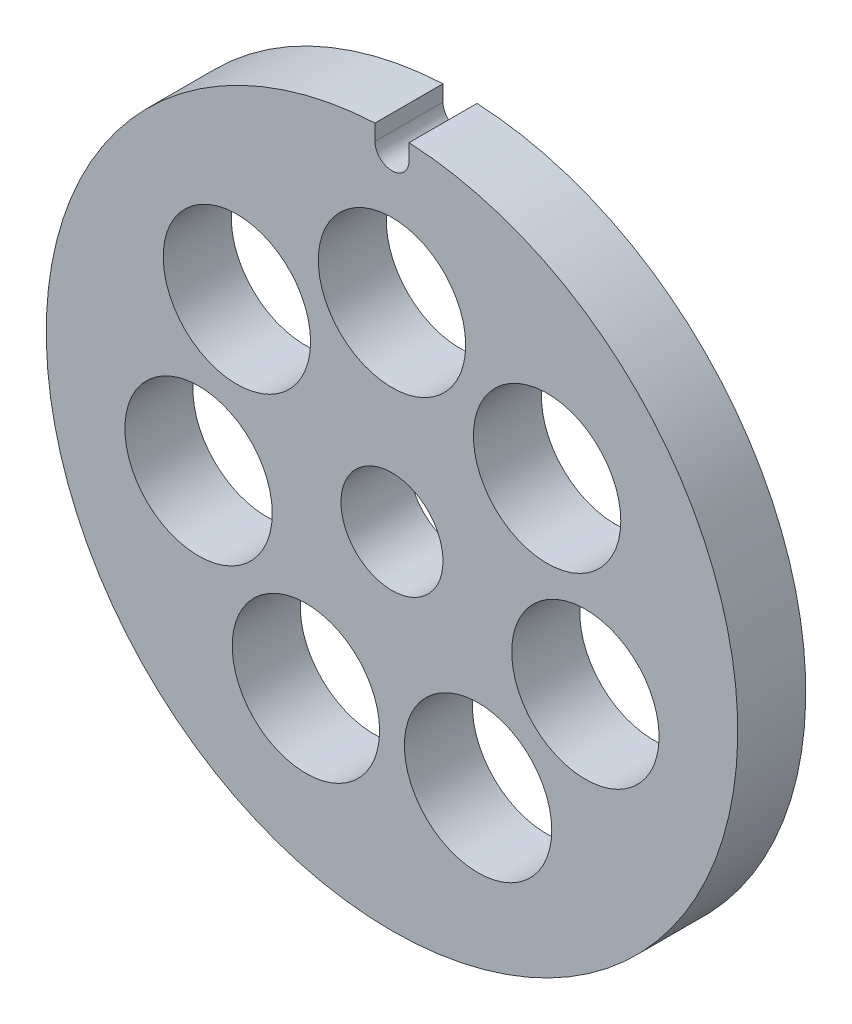
from build123d import *

# Parameters (mm, degrees)
SZKIC1_R                    = 4.5
SZKIC1_R_2                  = 6.5
DODANIE_WYCI_GNI_CIE1_DEPTH = 6


with BuildPart() as part:
    # Szkic1 → Dodanie-wyciągnięcie1 (new body)
    with BuildSketch(Plane.XY):
        with BuildLine():
            Line((-1.5, 29.063092423), (-1.5, 30.463092423))
            ThreePointArc((-1.5, 30.463092423), (0, -30.5), (1.5, 30.463092423))
            Line((1.5, 30.463092423), (1.5, 29.063092423))
            ThreePointArc((1.5, 29.063092423), (0, 27.563092423), (-1.5, 29.063092423))
        make_face()
        Circle(SZKIC1_R, mode=Mode.SUBTRACT)
        with Locations((0, 17.5)):
            Circle(SZKIC1_R_2, mode=Mode.SUBTRACT)
        with Locations((13.682050943, 10.911071533)):
            Circle(SZKIC1_R_2, mode=Mode.SUBTRACT)
        with Locations((17.061238463, -3.894116344)):
            Circle(SZKIC1_R_2, mode=Mode.SUBTRACT)
        with Locations((7.592965435, -15.766955188)):
            Circle(SZKIC1_R_2, mode=Mode.SUBTRACT)
        with Locations((-7.592965435, -15.766955188)):
            Circle(SZKIC1_R_2, mode=Mode.SUBTRACT)
        with Locations((-17.061238463, -3.894116344)):
            Circle(SZKIC1_R_2, mode=Mode.SUBTRACT)
        with Locations((-13.682050943, 10.911071533)):
            Circle(SZKIC1_R_2, mode=Mode.SUBTRACT)
    extrude(amount=DODANIE_WYCI_GNI_CIE1_DEPTH)


solid = part.part
